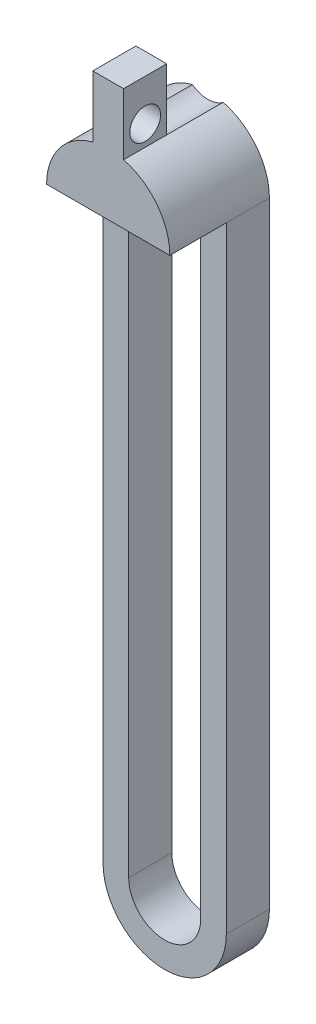
from build123d import *

# Parameters (mm, degrees)
EXTRUDE_1_DEPTH     = 4.2
EXTRUDE_2_DEPTH     = 5.5
CUT_EXTRUDE_1_DEPTH = 5.5
SKETCH_4_R          = 1.5
CUT_EXTRUDE_2_DEPTH = 10


with BuildPart() as part:
    # 草图1 → 凸台-拉伸1 (new body)
    with BuildSketch(Plane.XY):
        with BuildLine():
            Line((6.005, 3.173780296), (6.005, -56.826219704))
            ThreePointArc((6.005, -56.826219704), (0, -62.831219704), (-6.005, -56.826219704))
            Line((-6.005, -56.826219704), (-6.005, 3.173780296))
            ThreePointArc((-6.005, 3.173780296), (-4.746974036, 6.851587047), (-1.5, 8.988419149))
            Line((-1.5, 8.988419149), (-1.5, 14.988419149))
            Line((-1.5, 14.988419149), (1.5, 14.988419149))
            Line((1.5, 14.988419149), (1.5, 8.988419149))
            ThreePointArc((1.5, 8.988419149), (4.746974036, 6.851587047), (6.005, 3.173780296))
        make_face()
        with BuildLine():
            Line((3.505, 3.173780296), (3.505, -56.826219704))
            ThreePointArc((3.505, -56.826219704), (0, -60.331219704), (-3.505, -56.826219704))
            Line((-3.505, -56.826219704), (-3.505, 3.173780296))
            ThreePointArc((-3.505, 3.173780296), (0, 6.678780296), (3.505, 3.173780296))
        make_face(mode=Mode.SUBTRACT)
    extrude(amount=EXTRUDE_1_DEPTH)

    # 草图2 → 凸台-拉伸2 (add)
    with BuildSketch(Plane.XY.offset(4.2)):
        with BuildLine():
            Line((1.5, 14.988419149), (-1.5, 14.988419149))
            Line((-1.5, 14.988419149), (-1.5, 8.988419149))
            ThreePointArc((-1.5, 8.988419149), (-4.746974036, 6.851587047), (-6.005, 3.173780296))
            Line((-6.005, 3.173780296), (6.005, 3.173780296))
            ThreePointArc((6.005, 3.173780296), (4.746974036, 6.851587047), (1.5, 8.988419149))
            Line((1.5, 8.988419149), (1.5, 14.988419149))
        make_face()
    extrude(amount=EXTRUDE_2_DEPTH)

    # 草图3 → 切除-拉伸1 (cut)
    with BuildSketch(Plane(origin=(0, 0, 0), x_dir=(-1, 0, 0), z_dir=(0, 0, -1))):
        with BuildLine():
            Line((-1.5, 14.988419149), (1.5, 14.988419149))
            Line((1.5, 14.988419149), (1.5, 8.988419149))
            ThreePointArc((1.5, 8.988419149), (0, 8.488419149), (-1.5, 8.988419149))
            Line((-1.5, 8.988419149), (-1.5, 14.988419149))
        make_face()
    extrude(amount=-CUT_EXTRUDE_1_DEPTH, mode=Mode.SUBTRACT)

    # 草图4 → 切除-拉伸2 (cut)
    with BuildSketch(Plane(origin=(1.5, 0, 0), x_dir=(0, 0, -1), z_dir=(1, 0, 0))):
        with Locations((-7.6, 10.988419149)):
            Circle(SKETCH_4_R)
    extrude(amount=-CUT_EXTRUDE_2_DEPTH, mode=Mode.SUBTRACT)


solid = part.part
